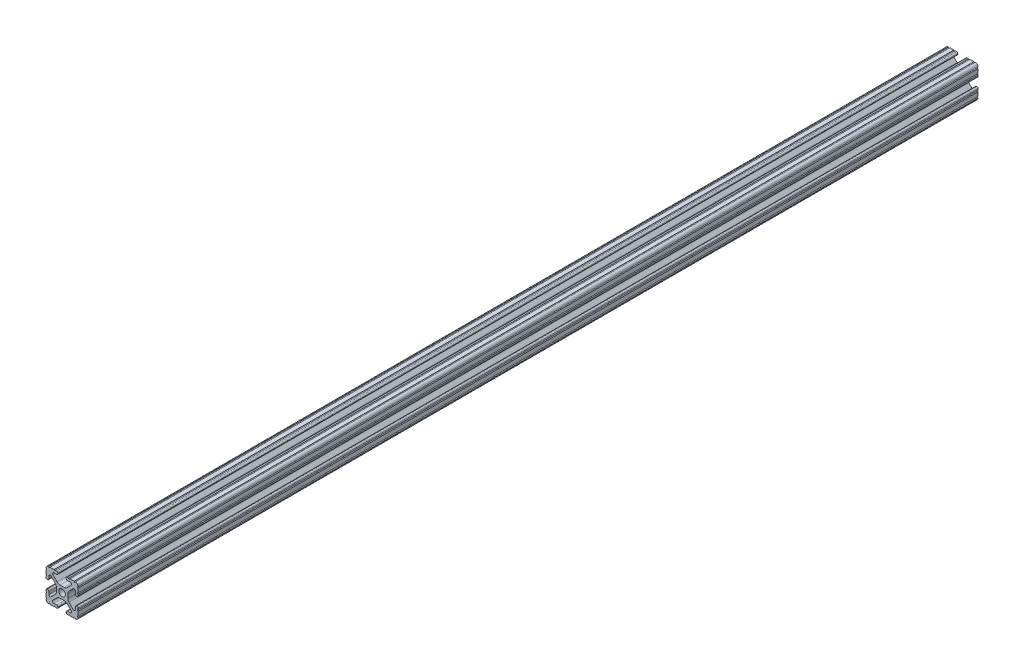
from build123d import *

# Parameters (mm, degrees)
SKETCH1_R           = 2.6035
BOSS_EXTRUDE1_DEPTH = 355.6


with BuildPart() as part:
    # Sketch1 → Boss-Extrude1 (new body, symmetric)
    with BuildSketch(Plane.XY):
        with BuildLine():
            Line((-7.179650497, -8.645192506), (-3.952270251, -5.423690499))
            ThreePointArc((-3.952270251, -5.423690499), (-2.922936451, -4.736929036), (-1.709253557, -4.4958))
            Line((-1.709253557, -4.4958), (1.709253557, -4.4958))
            ThreePointArc((1.709253557, -4.4958), (2.922936451, -4.736929036), (3.952270251, -5.423690499))
            Line((3.952270251, -5.423690499), (7.179650497, -8.645192506))
            ThreePointArc((7.179650497, -8.645192506), (7.41473083, -9.822813117), (6.416408329, -10.4902))
            Line((6.416408329, -10.4902), (4.287512407, -10.4902))
            ThreePointArc((4.287512407, -10.4902), (3.54574862, -10.79744862), (3.2385, -11.539212407))
            Line((3.2385, -11.539212407), (3.2385, -11.650987593))
            ThreePointArc((3.2385, -11.650987593), (3.54574862, -12.39275138), (4.287512407, -12.7))
            Line((4.287512407, -12.7), (5.317126718, -12.7))
            ThreePointArc((5.317126718, -12.7), (5.825126718, -12.192), (6.333126718, -12.7))
            Line((6.333126718, -12.7), (9.550443118, -12.7))
            ThreePointArc((9.550443118, -12.7), (10.058366869, -12.192000006), (10.566443095, -12.699847501))
            ThreePointArc((10.566443095, -12.699847501), (12.082537762, -12.08250727), (12.699846982, -10.566399977))
            ThreePointArc((12.699846982, -10.566399977), (12.192000006, -10.058323491), (12.7, -9.5504))
            Line((12.7, -9.5504), (12.7, -6.3330836))
            ThreePointArc((12.7, -6.3330836), (12.192, -5.8250836), (12.7, -5.3170836))
            Line((12.7, -5.3170836), (12.7, -4.287469289))
            ThreePointArc((12.7, -4.287469289), (12.39275138, -3.545705502), (11.650987593, -3.238456882))
            Line((11.650987593, -3.238456882), (11.539212407, -3.238456882))
            ThreePointArc((11.539212407, -3.238456882), (10.79744862, -3.545705502), (10.4902, -4.287469289))
            Line((10.4902, -4.287469289), (10.4902, -6.402089023))
            ThreePointArc((10.4902, -6.402089023), (9.856505071, -7.351067942), (8.737131347, -7.129408934))
            Line((8.737131347, -7.129408934), (5.441005833, -3.840816462))
            ThreePointArc((5.441005833, -3.840816462), (4.750877967, -2.809883091), (4.5085, -1.593185507))
            Line((4.5085, -1.593185507), (4.5085, 1.593185507))
            ThreePointArc((4.5085, 1.593185507), (4.750877967, 2.809883091), (5.441005833, 3.840816462))
            Line((5.441005833, 3.840816462), (8.737131347, 7.129408934))
            ThreePointArc((8.737131347, 7.129408934), (9.856505071, 7.351067942), (10.4902, 6.402089023))
            Line((10.4902, 6.402089023), (10.4902, 4.287469289))
            ThreePointArc((10.4902, 4.287469289), (10.79744862, 3.545705502), (11.539212407, 3.238456882))
            Line((11.539212407, 3.238456882), (11.650987593, 3.238456882))
            ThreePointArc((11.650987593, 3.238456882), (12.39275138, 3.545705502), (12.7, 4.287469289))
            Line((12.7, 4.287469289), (12.7, 5.3170836))
            ThreePointArc((12.7, 5.3170836), (12.192, 5.8250836), (12.7, 6.3330836))
            Line((12.7, 6.3330836), (12.7, 9.5504))
            ThreePointArc((12.7, 9.5504), (12.192000006, 10.058323491), (12.699846982, 10.566399977))
            ThreePointArc((12.699846982, 10.566399977), (12.082537762, 12.08250727), (10.566443095, 12.699847501))
            ThreePointArc((10.566443095, 12.699847501), (10.058366869, 12.192000006), (9.550443118, 12.7))
            Line((9.550443118, 12.7), (6.333126718, 12.7))
            ThreePointArc((6.333126718, 12.7), (5.825126718, 12.192), (5.317126718, 12.7))
            Line((5.317126718, 12.7), (4.287512407, 12.7))
            ThreePointArc((4.287512407, 12.7), (3.54574862, 12.39275138), (3.2385, 11.650987593))
            Line((3.2385, 11.650987593), (3.2385, 11.539212407))
            ThreePointArc((3.2385, 11.539212407), (3.54574862, 10.79744862), (4.287512407, 10.4902))
            Line((4.287512407, 10.4902), (6.476788598, 10.4902))
            ThreePointArc((6.476788598, 10.4902), (7.432222385, 9.85140422), (7.207036008, 8.724370562))
            Line((7.207036008, 8.724370562), (3.898272566, 5.423169045))
            ThreePointArc((3.898272566, 5.423169045), (2.869120213, 4.736787962), (1.655778399, 4.4958))
            Line((1.655778399, 4.4958), (-1.655778399, 4.4958))
            ThreePointArc((-1.655778399, 4.4958), (-2.869120213, 4.736787962), (-3.898272566, 5.423169045))
            Line((-3.898272566, 5.423169045), (-7.207036008, 8.724370562))
            ThreePointArc((-7.207036008, 8.724370562), (-7.432222385, 9.85140422), (-6.476788598, 10.4902))
            Line((-6.476788598, 10.4902), (-4.287512407, 10.4902))
            ThreePointArc((-4.287512407, 10.4902), (-3.54574862, 10.79744862), (-3.2385, 11.539212407))
            Line((-3.2385, 11.539212407), (-3.2385, 11.650987593))
            ThreePointArc((-3.2385, 11.650987593), (-3.54574862, 12.39275138), (-4.287512407, 12.7))
            Line((-4.287512407, 12.7), (-5.317126718, 12.7))
            ThreePointArc((-5.317126718, 12.7), (-5.825126718, 12.192), (-6.333126718, 12.7))
            Line((-6.333126718, 12.7), (-9.550443118, 12.7))
            ThreePointArc((-9.550443118, 12.7), (-10.058366869, 12.192000006), (-10.566443095, 12.699847501))
            ThreePointArc((-10.566443095, 12.699847501), (-12.082537762, 12.08250727), (-12.699846982, 10.566399977))
            ThreePointArc((-12.699846982, 10.566399977), (-12.192000006, 10.058323491), (-12.7, 9.5504))
            Line((-12.7, 9.5504), (-12.7, 6.3330836))
            ThreePointArc((-12.7, 6.3330836), (-12.192, 5.8250836), (-12.7, 5.3170836))
            Line((-12.7, 5.3170836), (-12.7, 4.287469289))
            ThreePointArc((-12.7, 4.287469289), (-12.39275138, 3.545705502), (-11.650987593, 3.238456882))
            Line((-11.650987593, 3.238456882), (-11.539212407, 3.238456882))
            ThreePointArc((-11.539212407, 3.238456882), (-10.79744862, 3.545705502), (-10.4902, 4.287469289))
            Line((-10.4902, 4.287469289), (-10.4902, 6.402089023))
            ThreePointArc((-10.4902, 6.402089023), (-9.856505071, 7.351067942), (-8.737131347, 7.129408934))
            Line((-8.737131347, 7.129408934), (-5.441005833, 3.840816462))
            ThreePointArc((-5.441005833, 3.840816462), (-4.750877967, 2.809883091), (-4.5085, 1.593185507))
            Line((-4.5085, 1.593185507), (-4.5085, -1.593185507))
            ThreePointArc((-4.5085, -1.593185507), (-4.750877967, -2.809883091), (-5.441005833, -3.840816462))
            Line((-5.441005833, -3.840816462), (-8.737131347, -7.129408934))
            ThreePointArc((-8.737131347, -7.129408934), (-9.856505071, -7.351067942), (-10.4902, -6.402089023))
            Line((-10.4902, -6.402089023), (-10.4902, -4.287469289))
            ThreePointArc((-10.4902, -4.287469289), (-10.79744862, -3.545705502), (-11.539212407, -3.238456882))
            Line((-11.539212407, -3.238456882), (-11.650987593, -3.238456882))
            ThreePointArc((-11.650987593, -3.238456882), (-12.39275138, -3.545705502), (-12.7, -4.287469289))
            Line((-12.7, -4.287469289), (-12.7, -5.3170836))
            ThreePointArc((-12.7, -5.3170836), (-12.192, -5.8250836), (-12.7, -6.3330836))
            Line((-12.7, -6.3330836), (-12.7, -9.5504))
            ThreePointArc((-12.7, -9.5504), (-12.192000006, -10.058323491), (-12.699846982, -10.566399977))
            ThreePointArc((-12.699846982, -10.566399977), (-12.082537762, -12.08250727), (-10.566443095, -12.699847501))
            ThreePointArc((-10.566443095, -12.699847501), (-10.058366869, -12.192000006), (-9.550443118, -12.7))
            Line((-9.550443118, -12.7), (-6.333126718, -12.7))
            ThreePointArc((-6.333126718, -12.7), (-5.825126718, -12.192), (-5.317126718, -12.7))
            Line((-5.317126718, -12.7), (-4.287512407, -12.7))
            ThreePointArc((-4.287512407, -12.7), (-3.54574862, -12.39275138), (-3.2385, -11.650987593))
            Line((-3.2385, -11.650987593), (-3.2385, -11.539212407))
            ThreePointArc((-3.2385, -11.539212407), (-3.54574862, -10.79744862), (-4.287512407, -10.4902))
            Line((-4.287512407, -10.4902), (-6.416408329, -10.4902))
            ThreePointArc((-6.416408329, -10.4902), (-7.41473083, -9.822813117), (-7.179650497, -8.645192506))
        make_face()
        Circle(SKETCH1_R, mode=Mode.SUBTRACT)
    extrude(amount=BOSS_EXTRUDE1_DEPTH, both=True)


solid = part.part
